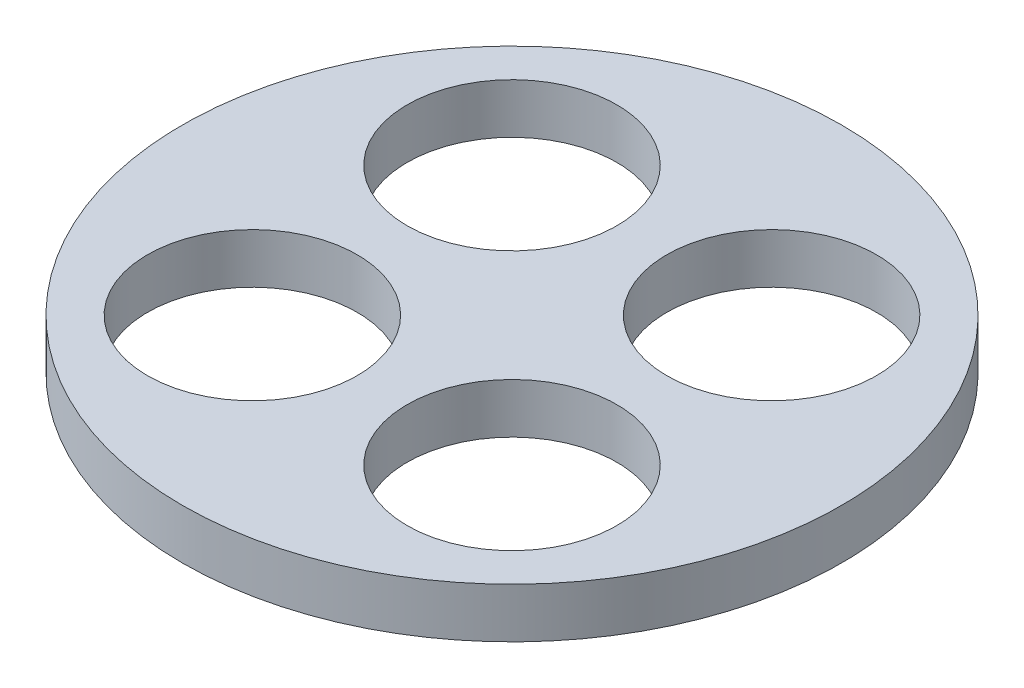
from build123d import *

# Parameters (mm, degrees)
SKETCH1_R           = 16.5
SKETCH1_R_2         = 5.25
BOSS_EXTRUDE1_DEPTH = 2.5


with BuildPart() as part:
    # Sketch1 → Boss-Extrude1 (new body)
    with BuildSketch(Plane(origin=(0, 0, 0), x_dir=(1, 0, 0), z_dir=(0, 1, 0))):
        Circle(SKETCH1_R)
        with Locations((6.5, -6.5)):
            Circle(SKETCH1_R_2, mode=Mode.SUBTRACT)
        with Locations((-6.5, -6.5)):
            Circle(SKETCH1_R_2, mode=Mode.SUBTRACT)
        with Locations((-6.5, 6.5)):
            Circle(SKETCH1_R_2, mode=Mode.SUBTRACT)
        with Locations((6.5, 6.5)):
            Circle(SKETCH1_R_2, mode=Mode.SUBTRACT)
    extrude(amount=BOSS_EXTRUDE1_DEPTH)


solid = part.part
